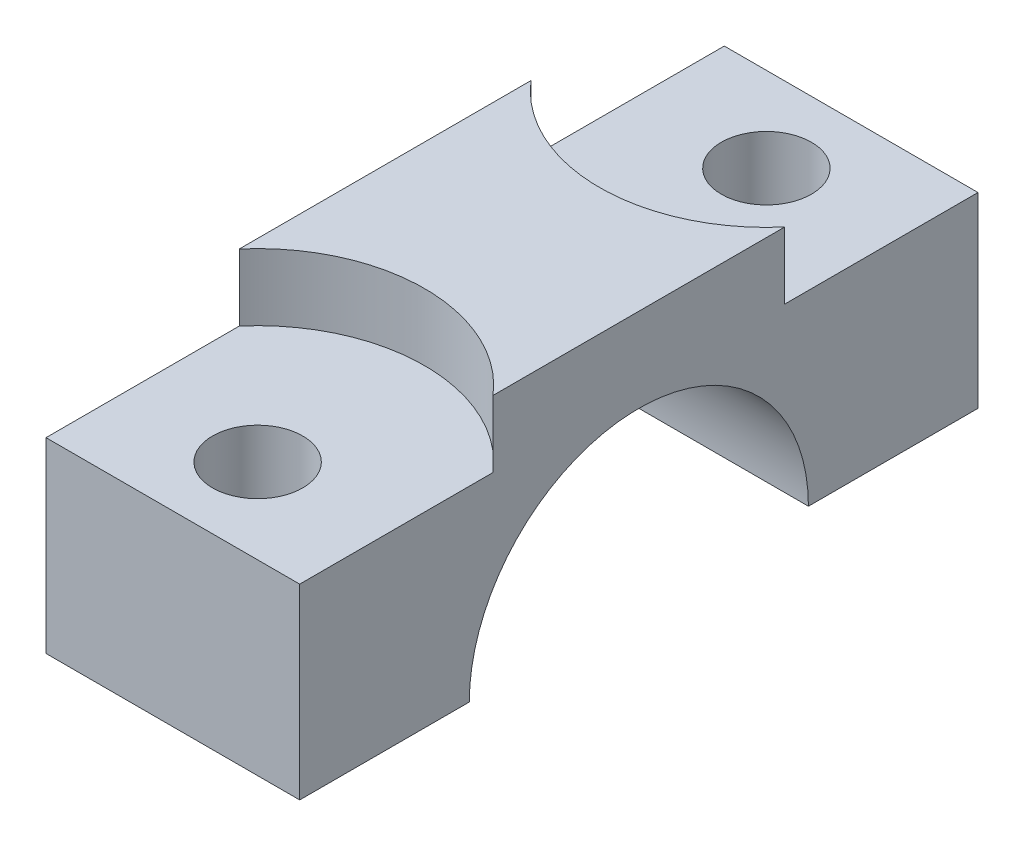
from build123d import *

# Parameters (mm, degrees)
BOSS_EXTRUDE1_DEPTH                           = 9.5
CBORE_FOR_M12_HEX_HEAD_CAP_SCREW1_D           = 6.75
CBORE_FOR_M12_HEX_HEAD_CAP_SCREW1_CBORE_D     = 25
CBORE_FOR_M12_HEX_HEAD_CAP_SCREW1_CBORE_DEPTH = 5


with BuildPart() as part:
    # Sketch1 → Boss-Extrude1 (new body, symmetric)
    with BuildSketch(Plane(origin=(0, 0, 0), x_dir=(0, 0, -1), z_dir=(1, 0, 0))):
        with BuildLine():
            Line((12.7, 0), (25.4, 0))
            Line((25.4, 0), (25.4, 19))
            Line((25.4, 19), (-25.4, 19))
            Line((-25.4, 19), (-25.4, 0))
            Line((-25.4, 0), (-12.7, 0))
            ThreePointArc((-12.7, 0), (0, 12.7), (12.7, 0))
        make_face()
    extrude(amount=BOSS_EXTRUDE1_DEPTH, both=True)

    # CBORE for M12 Hex Head Cap Screw1 (through all)
    with Locations(Plane(origin=(0, 19, 0), x_dir=(1, 0, 0), z_dir=(0, 1, 0))):
        with Locations((0, -19.05), (0, 19.05)):
            CounterBoreHole(CBORE_FOR_M12_HEX_HEAD_CAP_SCREW1_D / 2, CBORE_FOR_M12_HEX_HEAD_CAP_SCREW1_CBORE_D / 2, CBORE_FOR_M12_HEX_HEAD_CAP_SCREW1_CBORE_DEPTH)


solid = part.part
